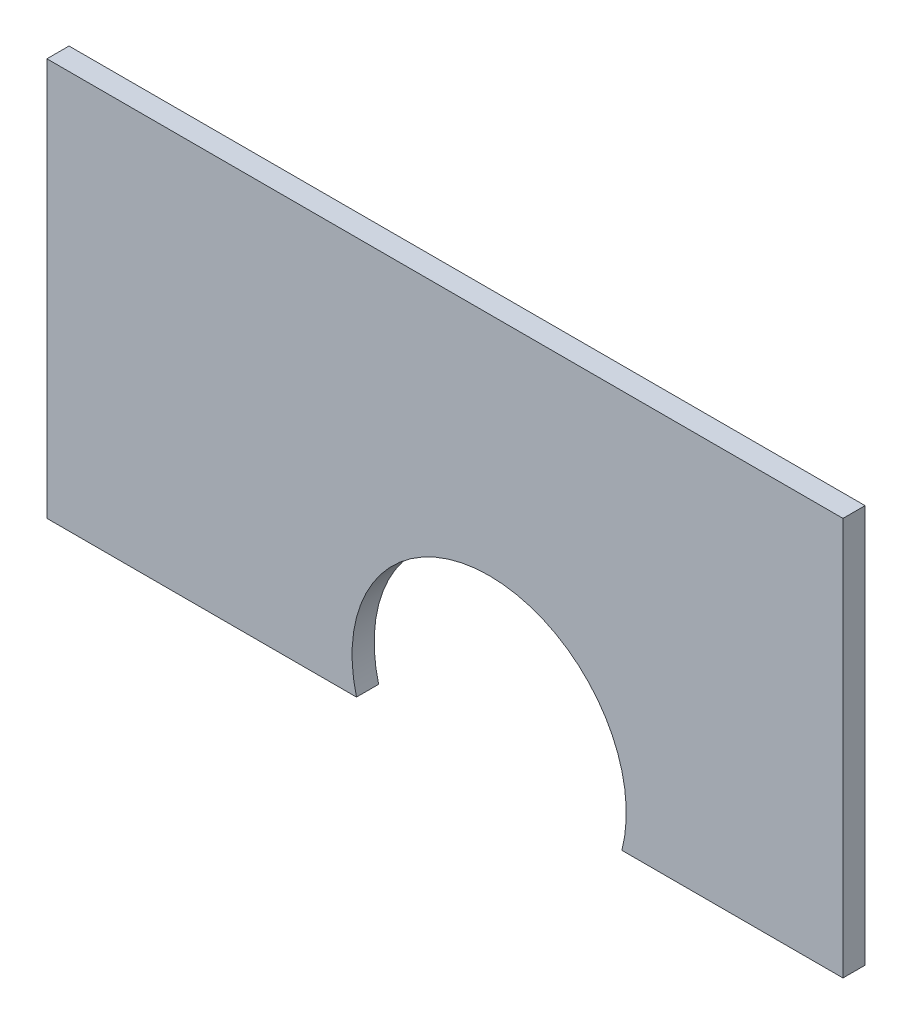
from build123d import *

# Parameters (mm, degrees)
BOSS_EXTRUDE1_DEPTH = 10


with BuildPart() as part:
    # Sketch2 → Boss-Extrude1 (new body)
    with BuildSketch(Plane.XY):
        with BuildLine():
            Line((-200, 164.379500648), (-200, -15.620499352))
            Line((-200, -15.620499352), (-60, -15.620499352))
            ThreePointArc((-60, -15.620499352), (0, 62), (60, -15.620499352))
            Line((60, -15.620499352), (160, -15.620499352))
            Line((160, -15.620499352), (160, 164.379500648))
            Line((160, 164.379500648), (-200, 164.379500648))
        make_face()
    extrude(amount=BOSS_EXTRUDE1_DEPTH)


solid = part.part
